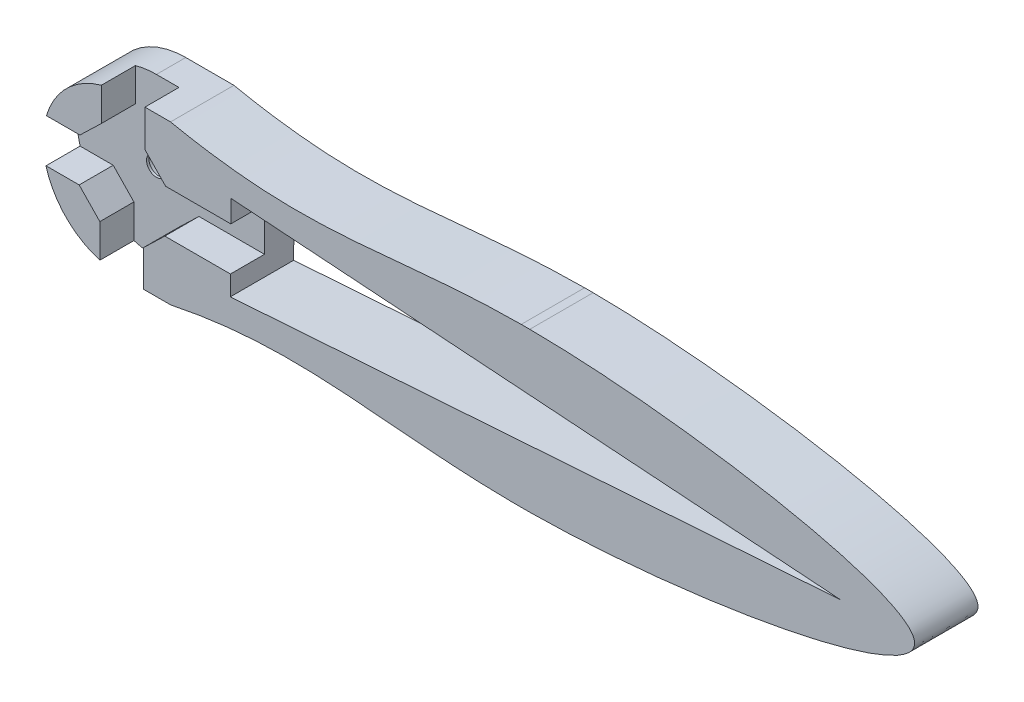
from build123d import *

# Parameters (mm, degrees)
BOSS_EXTRU_1_DEPTH       = 8
ESQUISSE13_R             = 4
ENL_V_MAT_EXTRU_9_DEPTH  = 4.3
ENL_V_MAT_EXTRU_10_DEPTH = 4.3
ESQUISSE15_R             = 2.5
ENL_V_MAT_EXTRU_11_DEPTH = 3.4
ENL_V_MAT_EXTRU_12_REACH = 113.898
ESQUISSE16_R             = 1.25
ESQUISSE17_OUTSIDE_W     = 146.384
ESQUISSE17_OUTSIDE_H     = 46.384
ENL_V_MAT_EXTRU_13_DEPTH = 10
ENL_V_MAT_EXTRU_14_DEPTH = 10


with BuildPart() as part:
    # Esquisse1 → Boss.-Extru.1 (new body)
    with BuildSketch(Plane.XY):
        with BuildLine():
            Line((0, 0), (100, 0))
            ThreePointArc((100, 0), (110, 10), (100, 20))
            Line((100, 20), (0, 20))
            ThreePointArc((0, 20), (-10, 10), (0, 0))
        make_face()
    extrude(amount=BOSS_EXTRU_1_DEPTH)

    # Esquisse13 → Enlèv. mat.-Extru.9 (cut)
    with BuildSketch(Plane.XY.offset(8)):
        with Locations((0, 10)):
            Circle(ESQUISSE13_R)
    extrude(amount=-ENL_V_MAT_EXTRU_9_DEPTH, mode=Mode.SUBTRACT)

    # Esquisse14 → Enlèv. mat.-Extru.10 (cut)
    with BuildSketch(Plane.XY.offset(8)):
        Polygon((2.655377087, 4.544050257), (2.655377087, -2.008601379), (-2.844622913, -1.912365766), (-2.844622913, 4.640285869), (-5.455949743, 7.344622913), (-12.008601379, 7.344622913), (-11.912365766, 12.844622913), (-5.359714131, 12.844622913), (-2.655377087, 15.455949743), (-2.655377087, 22.008601379), (2.844622913, 21.912365766), (2.844622913, 15.359714131), (5.455949743, 12.655377087), (12.008601379, 12.655377087), (17.818097103, 12.655377087), (17.818097103, 7.155377087), (11.912365766, 7.155377087), (5.359714131, 7.155377087), align=None)
    extrude(amount=-ENL_V_MAT_EXTRU_10_DEPTH, mode=Mode.SUBTRACT)

    # Esquisse15 → Enlèv. mat.-Extru.11 (cut)
    with BuildSketch(Plane(origin=(0, 0, 0), x_dir=(-1, 0, 0), z_dir=(0, 0, -1))):
        with Locations((0, 10)):
            Circle(ESQUISSE15_R)
    extrude(amount=-ENL_V_MAT_EXTRU_11_DEPTH, mode=Mode.SUBTRACT)

    # Esquisse16 → Enlèv. mat.-Extru.12 (cut, up to next)
    with BuildSketch(Plane(origin=(0, 0, 3.4), x_dir=(-1, 0, 0), z_dir=(0, 0, -1)), mode=Mode.PRIVATE) as enl_v_mat_extru_12_sk1:
        with Locations((0, 10)):
            Circle(ESQUISSE16_R)
    enl_v_mat_extru_12_tool1 = extrude(enl_v_mat_extru_12_sk1.sketch, amount=-ENL_V_MAT_EXTRU_12_REACH, mode=Mode.PRIVATE) & part.part
    add(enl_v_mat_extru_12_tool1.solids().sort_by_distance((0, 10, 3.4))[0], mode=Mode.SUBTRACT)

    # Esquisse17 outside → Enlèv. mat.-Extru.13 (cut)
    with BuildSketch(Plane.XY.offset(8)):
        with Locations((50, 10)):
            Rectangle(ESQUISSE17_OUTSIDE_W, ESQUISSE17_OUTSIDE_H)
        with BuildLine():
            add(Edge.make_bspline(
                [(6.078713642, 20), (24.915023514, 16.081550404), (43.772946516, 24.459557565), (129.172588167, 9.95529611), (44.539574838, -4.288408378), (17.569235721, 5.732265476), (-18.329346207, -7.417520102), (-23.15173951, 28.634629281), (-5.183949024, 22.342931088), (6.078713642, 20)],
                knots=[0, 0, 0, 0, 0.182524448, 0.382167519, 0.581810591, 0.764335038, 0.867297941, 0.890864437, 1, 1, 1, 1], degree=3))
        make_face(mode=Mode.SUBTRACT)
    extrude(amount=-ENL_V_MAT_EXTRU_13_DEPTH, mode=Mode.SUBTRACT)

    # Esquisse18 → Enlèv. mat.-Extru.14 (cut)
    with BuildSketch(Plane.XY.offset(8)):
        Polygon((13.616328718, 4.640285869), (13.71095163, 15.455949743), (90.655144278, 10.048117806), align=None)
    extrude(amount=-ENL_V_MAT_EXTRU_14_DEPTH, mode=Mode.SUBTRACT)


solid = part.part
